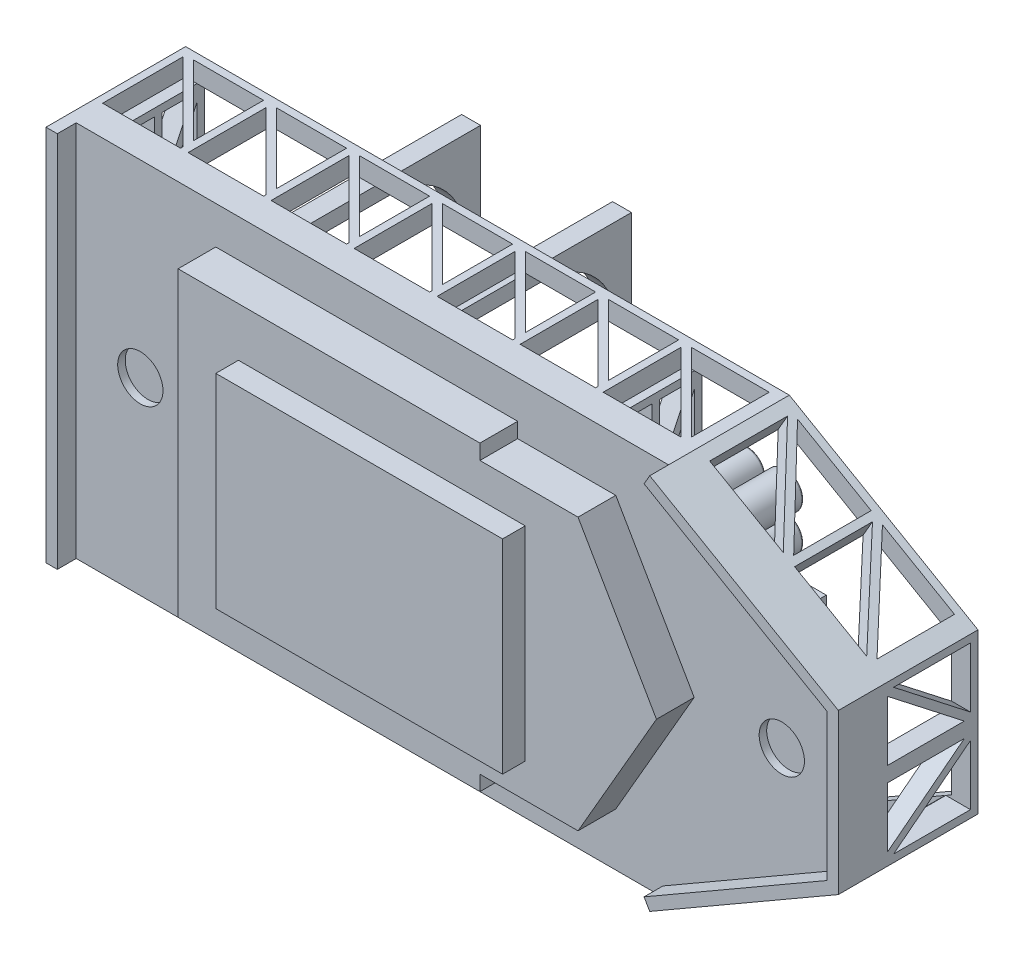
from build123d import *

# Parameters (mm, degrees)
BOSS_EXTRUDE1_DEPTH     = 2
BOSS_EXTRUDE2_DEPTH     = 13
CUT_EXTRUDE1_DEPTH      = 13
CUT_EXTRUDE2_DEPTH      = 13
CUT_EXTRUDE3_DEPTH      = 13
SKETCH6_W               = 2.5
SKETCH6_H               = 45
BOSS_EXTRUDE3_DEPTH     = 13
CUT_EXTRUDE4_DEPTH      = 6
SKETCH8_W               = 13
SKETCH8_H               = 20.425640275
CUT_EXTRUDE5_DEPTH      = 6
SKETCH9_W               = 2.5
SKETCH9_H               = 15
BOSS_EXTRUDE4_DEPTH     = 26
SKETCH11_R              = 3
BOSS_EXTRUDE6_DEPTH     = 1
SKETCH12_W              = 40
SKETCH12_H              = 40
BOSS_EXTRUDE7_DEPTH     = 5
BOSS_EXTRUDE8_DEPTH     = 5
SKETCH14_W              = 38
SKETCH14_H              = 26.999888524
BOSS_EXTRUDE9_DEPTH     = 3
SKETCH15_W              = 1.5
SKETCH15_H              = 50
BOSS_EXTRUDE10_DEPTH    = 2.5
CUT_EXTRUDE6_DEPTH      = 5
LPATTERN1_COUNT         = 2
LPATTERN1_PITCH         = 20
MIRROR3_COPY_1_SKETCH_W = 2.5
MIRROR3_COPY_1_SKETCH_H = 15
MIRROR3_COPY_1_DEPTH    = 26
MIRROR3_COPY_2_DEPTH    = 5
SKETCH17_R              = 4.5
BOSS_EXTRUDE11_DEPTH    = 5
BOSS_EXTRUDE14_DEPTH    = 7.5
BOSS_EXTRUDE15_DEPTH    = 4.5
SKETCH17_8_R            = 2.4
BOSS_EXTRUDE19_DEPTH    = 14.5
FILLET3_R               = 0.25
FILLET4_R               = 0.5


with BuildPart() as part:
    # Sketch1 → Boss-Extrude1 (new body)
    with BuildSketch(Plane.XY):
        Polygon((-40, -25), (40, -25), (65, -10.56624327), (65, 10.56624327), (40, 25), (-40, 25), align=None)
    extrude(amount=-BOSS_EXTRUDE1_DEPTH)

    # Sketch2 → Boss-Extrude2 (add)
    with BuildSketch(Plane(origin=(0, 0, -2), x_dir=(-1, 0, 0), z_dir=(0, 0, -1))):
        Polygon((37.5, 22.5), (-39.330127019, 22.5), (-62.5, 9.122867597), (-62.5, 0), (-65, 0), (-65, 10.56624327), (-40, 25), (40, 25), (40, 22.5), align=None)
    boss_extrude2 = extrude(amount=BOSS_EXTRUDE2_DEPTH)

    # Sketch3 → Cut-Extrude1 (cut)
    with BuildSketch(Plane.XZ.offset(-22.5)):
        Polygon((38.330127019, -14), (28.0372338, -14), (38.330127019, -3.707106781), align=None)
        Polygon((-39, -13.623020238), (-39, -3), (-28.669872981, -3), (-28.669872981, -3.292893219), (-38.669872981, -13.292893219), align=None)
        Polygon((27.330127019, -13.292893219), (27.330127019, -3), (37.623020238, -3), align=None)
        Polygon((26.330127019, -14), (26.330127019, -4.707106781), (17.0372338, -14), align=None)
        Polygon((16.330127019, -13.292893219), (16.330127019, -3), (26.330127019, -3), (26.330127019, -3.292893219), align=None)
        Polygon((15.330127019, -14), (15.330127019, -4.707106781), (6.0372338, -14), align=None)
        Polygon((5.330127019, -13.292893219), (5.330127019, -3), (15.330127019, -3), (15.330127019, -3.292893219), align=None)
        Polygon((4.330127019, -14), (4.330127019, -4.707106781), (-4.9627662, -14), align=None)
        Polygon((-5.669872981, -13.292893219), (-5.669872981, -3), (4.330127019, -3), (4.330127019, -3.292893219), align=None)
        Polygon((-6.669872981, -14), (-6.669872981, -4.707106781), (-15.9627662, -14), align=None)
        Polygon((-16.669872981, -13.292893219), (-16.669872981, -3), (-6.669872981, -3), (-6.669872981, -3.292893219), align=None)
        Polygon((-17.669872981, -14), (-17.669872981, -4.707106781), (-26.9627662, -14), align=None)
        Polygon((-27.669872981, -13.292893219), (-27.669872981, -3), (-17.669872981, -3), (-17.669872981, -3.292893219), align=None)
        Polygon((-28.669872981, -14), (-28.669872981, -4.707106781), (-37.9627662, -14), align=None)
    cut_extrude1 = extrude(amount=-CUT_EXTRUDE1_DEPTH, mode=Mode.SUBTRACT)

    # Sketch4 → Cut-Extrude2 (cut)
    with BuildSketch(Plane(origin=(19.575317547, 33.905444566, 0), x_dir=(0.8660254037844379, -0.5000000000000013, 0), z_dir=(-0.5000000000000013, -0.8660254037844379, 0))):
        Polygon((23.810889132, -3), (23.810889132, -13.321715808), (35.070942742, -3), align=None)
        Polygon((24.550835523, -14), (35.810889132, -14), (35.810889132, -3.73715414), align=None)
        Polygon((48.565153938, -14), (48.565153938, -3.730145122), (37.542640599, -14), align=None)
        Polygon((47.833402471, -3), (36.810889132, -3), (36.810889132, -13.315204629), align=None)
    cut_extrude2 = extrude(amount=-CUT_EXTRUDE2_DEPTH, mode=Mode.SUBTRACT)

    # Sketch5 → Cut-Extrude3 (cut)
    with BuildSketch(Plane(origin=(65, 0, 0), x_dir=(0, 0, -1), z_dir=(1, 0, 0))):
        Polygon((14, 9.56624327), (3.813778056, 9.56624327), (14, 1.633729163), align=None)
        Polygon((13.186221944, 1), (3, 1), (3, 8.932514107), align=None)
    cut_extrude3 = extrude(amount=-CUT_EXTRUDE3_DEPTH, mode=Mode.SUBTRACT)

    # Mirror1: Boss-Extrude2, Cut-Extrude1, Cut-Extrude2, Cut-Extrude3 across plane
    add(boss_extrude2.mirror(Plane(origin=(62.5, 0, -15), x_dir=(0, 0, 1), z_dir=(0, 1, 0))))
    add(cut_extrude1.mirror(Plane(origin=(62.5, 0, -15), x_dir=(0, 0, 1), z_dir=(0, 1, 0))), mode=Mode.SUBTRACT)
    add(cut_extrude2.mirror(Plane(origin=(62.5, 0, -15), x_dir=(0, 0, 1), z_dir=(0, 1, 0))), mode=Mode.SUBTRACT)
    add(cut_extrude3.mirror(Plane(origin=(62.5, 0, -15), x_dir=(0, 0, 1), z_dir=(0, 1, 0))), mode=Mode.SUBTRACT)

    # Sketch6 → Boss-Extrude3 (add)
    with BuildSketch(Plane(origin=(0, 0, -2), x_dir=(-1, 0, 0), z_dir=(0, 0, -1))):
        with Locations((-27.15263918, 0)):
            Rectangle(SKETCH6_W, SKETCH6_H)
    boss_extrude3 = extrude(amount=BOSS_EXTRUDE3_DEPTH)

    # Sketch7 → Cut-Extrude4 (cut)
    with BuildSketch(Plane.ZY.offset(-25.90263918)):
        Polygon((-14, -11.637062491), (-14, -19.176261192), (-9.970184912, -11.637062491), align=None)
        Polygon((-8.375, -12.960649892), (-8.375, -21.5), (-4.303914483, -21.5), align=None)
        Polygon((-9.375, 21.5), (-13.446085517, 21.5), (-9.375, 12.960649892), align=None)
        Polygon((-3.75, 10.788577784), (-3.75, 19.378656676), (-8.341526355, 10.788577784), align=None)
        Polygon((-14.10818343, -21.5), (-9.375, -21.5), (-9.375, -12.644901295), align=None)
        Polygon((-14, -1.161869404), (-14, -10.637062491), (-9.482756784, -10.637062491), align=None)
        Polygon((-10.009931303, 9.788577784), (-14, 9.788577784), (-14, 2.323738808), align=None)
        Polygon((-14, 20.338130596), (-14, 10.788577784), (-9.447306217, 10.788577784), align=None)
        Polygon((-7.898183631, -11.637062491), (-3.75, -20.338130596), (-3.75, -11.637062491), align=None)
        Polygon((-8.375, 12.847296779), (-3.75, 21.5), (-8.375, 21.5), align=None)
        Polygon((-3.75, -2.121343324), (-8.301779963, -10.637062491), (-3.75, -10.637062491), align=None)
        Polygon((-13.207713424, -0.5), (-9.375, -8.539350108), (-9.375, -0.5), align=None)
        Polygon((-8.375, -0.5), (-8.375, -8.652703221), (-4.01725752, -0.5), align=None)
        Polygon((-8.375, 8.539350108), (-8.375, 0.5), (-4.542286576, 0.5), align=None)
        Polygon((-13.84092591, 0.5), (-9.375, 0.5), (-9.375, 8.855098705), align=None)
        Polygon((-3.75, 9.788577784), (-7.862733065, 9.788577784), (-3.75, 1.161869404), align=None)
    cut_extrude4 = extrude(amount=-CUT_EXTRUDE4_DEPTH, mode=Mode.SUBTRACT)

    # Mirror2: Boss-Extrude3, Cut-Extrude4 across plane
    add(boss_extrude3.mirror(Plane(origin=(-5.79736082, 0, 0), x_dir=(0, 0, 1), z_dir=(1, 0, 0))))
    add(cut_extrude4.mirror(Plane(origin=(-5.79736082, 0, 0), x_dir=(0, 0, 1), z_dir=(1, 0, 0))), mode=Mode.SUBTRACT)

    # Sketch8 → Cut-Extrude5 (cut)
    with BuildSketch(Plane.ZY.offset(39.99736082)):
        with Locations((-8.5, -0.424242353)):
            Rectangle(SKETCH8_W, SKETCH8_H)
    extrude(amount=-CUT_EXTRUDE5_DEPTH, mode=Mode.SUBTRACT)

    # Sketch9 → Boss-Extrude4 (add)
    with BuildSketch(Plane(origin=(0, 0, -2), x_dir=(-1, 0, 0), z_dir=(0, 0, -1))):
        with Locations((-4.82946252, 15)):
            Rectangle(SKETCH9_W, SKETCH9_H)
    boss_extrude4 = extrude(amount=BOSS_EXTRUDE4_DEPTH)

    # Sketch11 → Boss-Extrude6 (add)
    with BuildSketch(Plane.XY):
        Polygon((-40, -25), (40, -25), (65, -10.56624327), (65, 10.56624327), (40, 25), (-40, 25), align=None)
        with Locations((55, 0)):
            Circle(SKETCH11_R, mode=Mode.SUBTRACT)
        with Locations((-30, 0)):
            Circle(SKETCH11_R, mode=Mode.SUBTRACT)
    extrude(amount=BOSS_EXTRUDE6_DEPTH)

    # Sketch12 → Boss-Extrude7 (add)
    with BuildSketch(Plane.XY.offset(1)):
        Rectangle(SKETCH12_W, SKETCH12_H)
    extrude(amount=BOSS_EXTRUDE7_DEPTH)

    # Sketch13 → Boss-Extrude8 (add)
    with BuildSketch(Plane.XY.offset(1)):
        Polygon((20, 18), (33, 18), (43.392304845, 0), (33, -18), (20, -18), align=None)
    extrude(amount=BOSS_EXTRUDE8_DEPTH)

    # Sketch14 → Boss-Extrude9 (add)
    with BuildSketch(Plane.XY.offset(6)):
        with Locations((7, 0)):
            Rectangle(SKETCH14_W, SKETCH14_H)
    extrude(amount=BOSS_EXTRUDE9_DEPTH)

    # Sketch15 → Boss-Extrude10 (add)
    with BuildSketch(Plane.XY.offset(1)):
        with Locations((-39.25, 0)):
            Rectangle(SKETCH15_W, SKETCH15_H)
        Polygon((40, -25), (65, -10.56624327), (65, 10.56624327), (40, 25), (39.25, 23.700961894), (63.5, 9.700217866), (63.5, -9.700217866), (39.25, -23.700961894), align=None)
    extrude(amount=BOSS_EXTRUDE10_DEPTH)

    # Sketch16 → Cut-Extrude6 (cut)
    with BuildSketch(Plane.ZY.offset(-3.57946252)):
        with BuildLine():
            Line((-2, 7.5), (-26, 7.5))
            Line((-26, 7.5), (-28, 7.5))
            Line((-28, 7.5), (-28, 10.5))
            Line((-28, 10.5), (-26, 10.5))
            ThreePointArc((-26, 10.5), (-23.071067812, 17.571067812), (-16, 20.5))
            Line((-16, 20.5), (-2, 20.5))
            Line((-2, 20.5), (-2, 7.5))
        make_face()
    cut_extrude6 = extrude(amount=-CUT_EXTRUDE6_DEPTH, mode=Mode.SUBTRACT)

    # LPattern1: Boss-Extrude4, Cut-Extrude6 ×2
    with Locations(*[(-i * LPATTERN1_PITCH, 0, 0) for i in range(1, LPATTERN1_COUNT)]):
        add(boss_extrude4)
        add(cut_extrude6, mode=Mode.SUBTRACT)

    # Mirror3: Boss-Extrude4, Cut-Extrude6 across plane
    add(boss_extrude4.mirror(Plane.ZX))
    add(cut_extrude6.mirror(Plane.ZX), mode=Mode.SUBTRACT)

    # Mirror3 copy 1 sketch → Mirror3 copy 1 (add)
    with BuildSketch(Plane(origin=(-20, 0, -2), x_dir=(-1, 0, 0), z_dir=(0, 0, -1))):
        with Locations((-4.82946252, -15)):
            Rectangle(MIRROR3_COPY_1_SKETCH_W, MIRROR3_COPY_1_SKETCH_H)
    extrude(amount=MIRROR3_COPY_1_DEPTH)

    # Mirror3 copy 2 sketch → Mirror3 copy 2 (cut)
    with BuildSketch(Plane.ZY.offset(16.42053748)):
        with BuildLine():
            Line((-2, -7.5), (-26, -7.5))
            Line((-26, -7.5), (-28, -7.5))
            Line((-28, -7.5), (-28, -10.5))
            Line((-28, -10.5), (-26, -10.5))
            ThreePointArc((-26, -10.5), (-23.071067812, -17.571067812), (-16, -20.5))
            Line((-16, -20.5), (-2, -20.5))
            Line((-2, -20.5), (-2, -7.5))
        make_face()
    extrude(amount=-MIRROR3_COPY_2_DEPTH, mode=Mode.SUBTRACT)

    # Sketch17 → Boss-Extrude11 (add)
    with BuildSketch(Plane(origin=(0, 0, -2), x_dir=(-1, 0, 0), z_dir=(0, 0, -1))):
        with Locations((-55, 0)):
            Circle(SKETCH17_R)
    extrude(amount=BOSS_EXTRUDE11_DEPTH)

    # Sketch17_4 → Boss-Extrude14 (add)
    with BuildSketch(Plane(origin=(0, 0, -2), x_dir=(-1, 0, 0), z_dir=(0, 0, -1))):
        Polygon((-50.4, -9.9), (-50.4, -10), (-41, -10), (-40.6, -10), (-40.6, 10), (-41, 10), (-50.4, 10), (-50.4, 9.9), align=None)
    extrude(amount=BOSS_EXTRUDE14_DEPTH)

    # Sketch17_5 → Boss-Extrude15 (add)
    with BuildSketch(Plane(origin=(0, 0, -2), x_dir=(-1, 0, 0), z_dir=(0, 0, -1))):
        Polygon((-40.6, -10), (-41, -10), (-41, -15.5), (-30, -15.5), (-30, 15.5), (-41, 15.5), (-41, 10), (-40.6, 10), (-40.6, 10.1), (-40.6, 15.1), (-30.4, 15.1), (-30.4, -15.1), (-40.6, -15.1), (-40.6, -10.1), align=None)
    extrude(amount=BOSS_EXTRUDE15_DEPTH)

    # Sketch17_8 → Boss-Extrude19 (add)
    with BuildSketch(Plane(origin=(0, 0, -2), x_dir=(-1, 0, 0), z_dir=(0, 0, -1))):
        with Locations((-33, 12.5)):
            Circle(SKETCH17_8_R)
        with Locations((-33, 7.5)):
            Circle(SKETCH17_8_R)
        with Locations((-33, 2.5)):
            Circle(SKETCH17_8_R)
        with Locations((-33, -2.5)):
            Circle(SKETCH17_8_R)
        with Locations((-33, -7.5)):
            Circle(SKETCH17_8_R)
        with Locations((-33, -12.5)):
            Circle(SKETCH17_8_R)
        with Locations((-38, 12.5)):
            Circle(SKETCH17_8_R)
        with Locations((-38, 7.5)):
            Circle(SKETCH17_8_R)
        with Locations((-38, 2.5)):
            Circle(SKETCH17_8_R)
        with Locations((-38, -2.5)):
            Circle(SKETCH17_8_R)
        with Locations((-38, -7.5)):
            Circle(SKETCH17_8_R)
        with Locations((-38, -12.5)):
            Circle(SKETCH17_8_R)
    extrude(amount=BOSS_EXTRUDE19_DEPTH)

    # Fillet3
    fillet3_edges = [part.edges().sort_by_distance(p)[0] for p in [
        (35.4, -12.5, -16.5),
        (35.4, -7.5, -16.5),
        (35.4, -2.5, -16.5),
        (35.4, 2.5, -16.5),
        (35.4, 7.5, -16.5),
        (35.4, 12.5, -16.5),
        (40.4, -12.5, -16.5),
        (40.4, -7.5, -16.5),
        (40.4, -2.5, -16.5),
        (40.4, 2.5, -16.5),
        (40.4, 7.5, -16.5),
        (40.4, 12.5, -16.5),
    ]]
    fillet(fillet3_edges, radius=FILLET3_R)

    # Fillet4
    fillet4_edges = [part.edges().sort_by_distance(p)[0] for p in [
        (59.5, 0, -7),
    ]]
    fillet(fillet4_edges, radius=FILLET4_R)


solid = part.part
